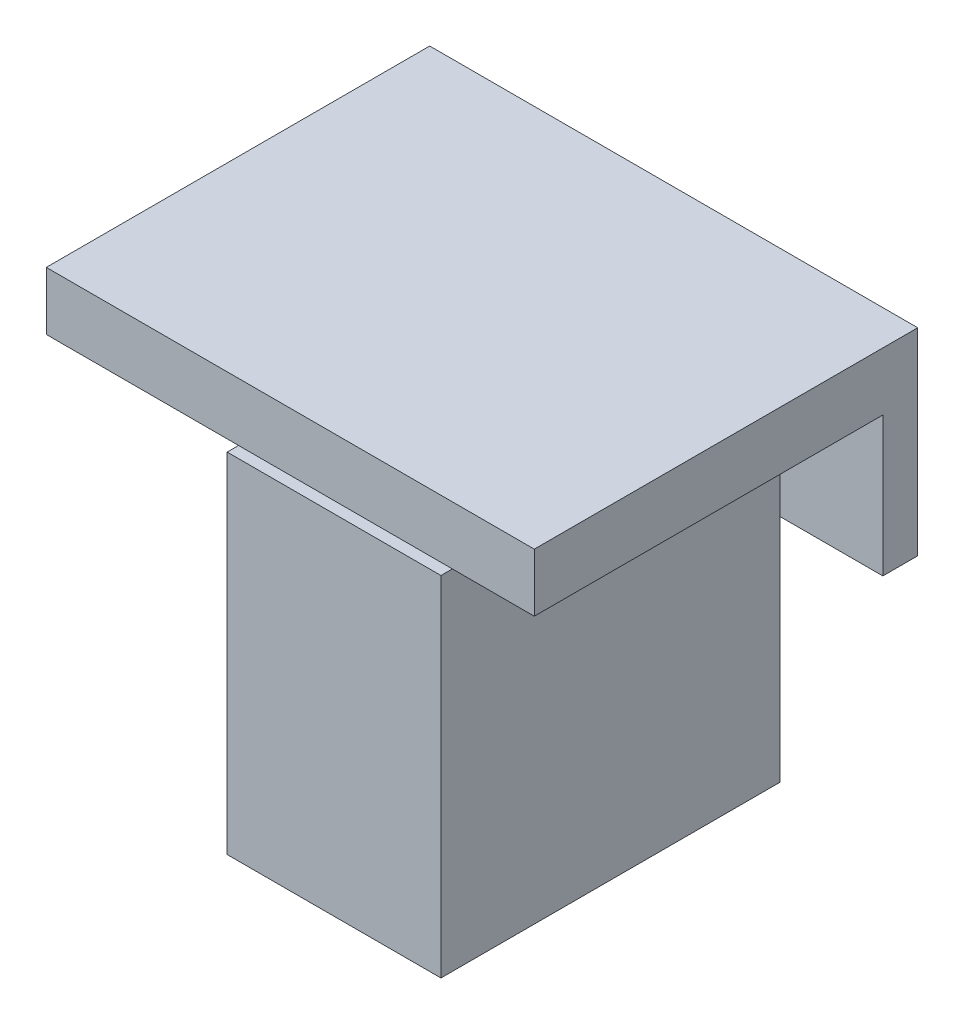
from build123d import *

# Parameters (mm, degrees)
ESQUISSE1_W             = 42
ESQUISSE1_H             = 17
BOSS_EXTRU_1_DEPTH      = 3
ESQUISSE2_R             = 1.625
ENL_V_MAT_EXTRU_1_DEPTH = 4
ESQUISSE3_W             = 42
ESQUISSE3_H             = 5
BOSS_EXTRU_2_DEPTH      = 30
ESQUISSE4_W             = 18.4
ESQUISSE4_H             = 29.2
ESQUISSE4_W_2           = 12.4
ESQUISSE4_H_2           = 23.2
BOSS_EXTRU_3_DEPTH      = 30


with BuildPart() as part:
    # Esquisse1 → Boss.-Extru.1 (new body)
    with BuildSketch(Plane.XY):
        with Locations((21, -8.5)):
            Rectangle(ESQUISSE1_W, ESQUISSE1_H)
    extrude(amount=BOSS_EXTRU_1_DEPTH)

    # Esquisse2 → Enlèv. mat.-Extru.1 (cut, through all)
    with BuildSketch(Plane.XY.offset(3)):
        with Locations((6, -8.5)):
            Circle(ESQUISSE2_R)
        with Locations((36, -8.5)):
            Circle(ESQUISSE2_R)
    extrude(amount=-ENL_V_MAT_EXTRU_1_DEPTH, mode=Mode.SUBTRACT)

    # Esquisse3 → Boss.-Extru.2 (add)
    with BuildSketch(Plane.XY.offset(3)):
        with Locations((21, -2.5)):
            Rectangle(ESQUISSE3_W, ESQUISSE3_H)
    extrude(amount=BOSS_EXTRU_2_DEPTH)

    # Esquisse4 → Boss.-Extru.3 (add)
    with BuildSketch(Plane.XZ.offset(5)):
        with Locations((25.749828538, 19.382668745)):
            Rectangle(ESQUISSE4_W, ESQUISSE4_H)
        with Locations((25.749828538, 19.382668745)):
            Rectangle(ESQUISSE4_W_2, ESQUISSE4_H_2, mode=Mode.SUBTRACT)
    extrude(amount=BOSS_EXTRU_3_DEPTH)


solid = part.part
